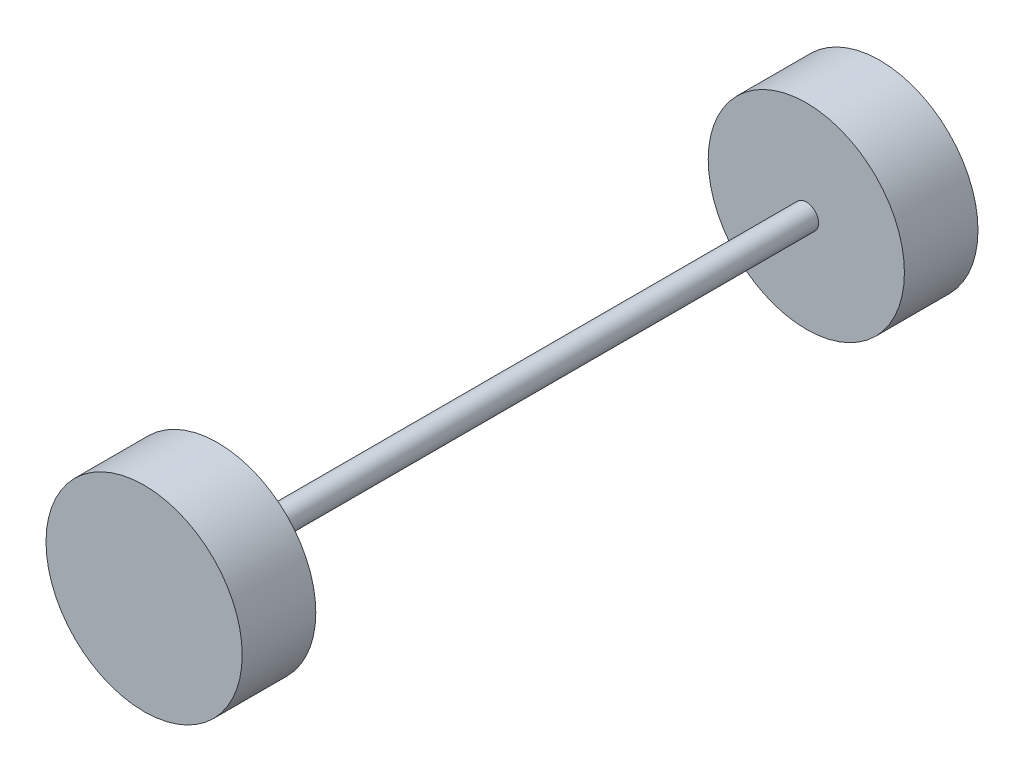
from build123d import *

# Parameters (mm, degrees)
SKETCH1_R           = 101.6
BOSS_EXTRUDE1_DEPTH = 76.2
SKETCH2_R           = 12.7
BOSS_EXTRUDE2_DEPTH = 609.6


with BuildPart() as part:
    # Sketch1 → Boss-Extrude1 (new body)
    with BuildSketch(Plane.XY):
        Circle(SKETCH1_R)
    boss_extrude1 = extrude(amount=BOSS_EXTRUDE1_DEPTH)

    # Sketch2 → Boss-Extrude2 (add)
    with BuildSketch(Plane.XY.offset(76.2)):
        Circle(SKETCH2_R)
    extrude(amount=BOSS_EXTRUDE2_DEPTH)

    # Mirror1: Boss-Extrude1 across plane
    add(boss_extrude1.mirror(Plane.XY.offset(381)))


solid = part.part
